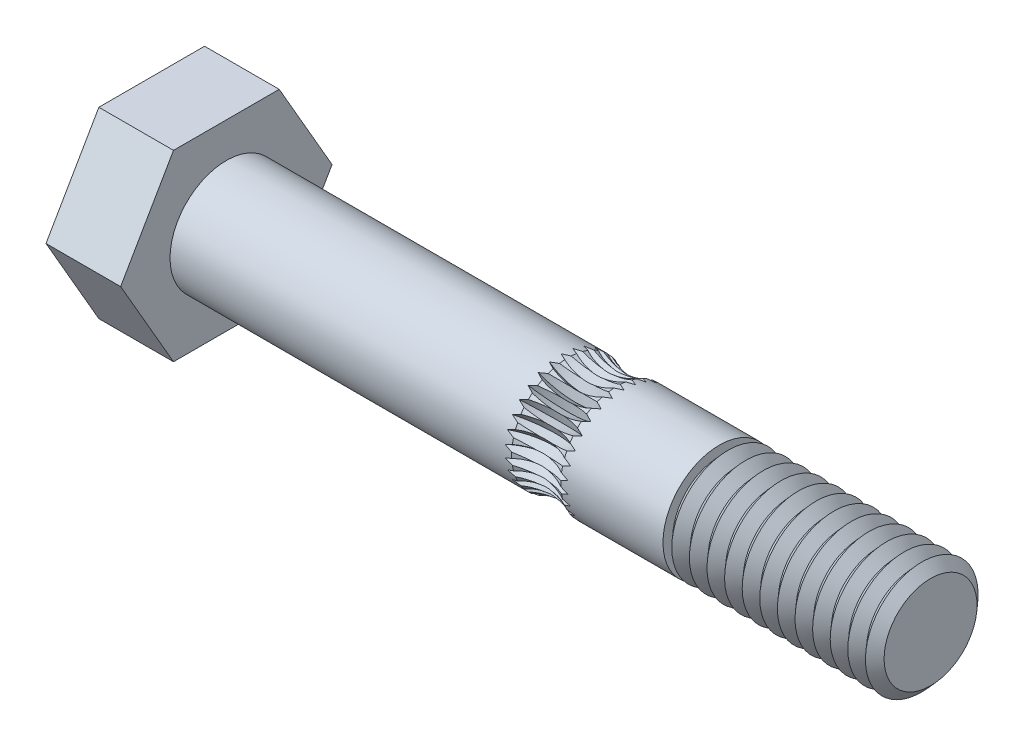
from build123d import *

# Parameters (mm, degrees)
SKETCH2_OUTSIDE_W  = 36.232
SKETCH2_OUTSIDE_H  = 36.232
CUT_EXTRUDE1_DEPTH = 66.3
CIRPATTERN1_COUNT  = 30
SKETCH4_R          = 8.784021567
CUT_EXTRUDE2_DEPTH = 10


with BuildPart() as part:
    # Sketch1 → Revolve1 (revolve)
    with BuildSketch(Plane.XY, mode=Mode.PRIVATE) as revolve1_sk:
        with BuildLine():
            Line((0, 0), (0, 10))
            Line((0, 10), (5.3, 10))
            Line((5.3, 10), (5.3, 4))
            Line((5.3, 4), (29.556440423, 4))
            ThreePointArc((29.556440423, 4), (31.3, 3.6), (33.043559577, 4))
            Line((33.043559577, 4), (40.3, 4))
            Line((40.3, 4), (40.3, 3.3))
            Line((40.3, 3.3), (40.925, 4))
            Line((40.925, 4), (41.55, 3.3))
            Line((41.55, 3.3), (42.175, 4))
            Line((42.175, 4), (42.8, 3.3))
            Line((42.8, 3.3), (43.425, 4))
            Line((43.425, 4), (44.05, 3.3))
            Line((44.05, 3.3), (44.675, 4))
            Line((44.675, 4), (45.3, 3.3))
            Line((45.3, 3.3), (45.925, 4))
            Line((45.925, 4), (46.55, 3.3))
            Line((46.55, 3.3), (47.175, 4))
            Line((47.175, 4), (47.8, 3.3))
            Line((47.8, 3.3), (48.425, 4))
            Line((48.425, 4), (49.05, 3.3))
            Line((49.05, 3.3), (49.675, 4))
            Line((49.675, 4), (50.3, 3.3))
            Line((50.3, 3.3), (50.925, 4))
            Line((50.925, 4), (51.55, 3.3))
            Line((51.55, 3.3), (52.175, 4))
            Line((52.175, 4), (52.8, 3.3))
            Line((52.8, 3.3), (53.425, 4))
            Line((53.425, 4), (54.05, 3.3))
            Line((54.05, 3.3), (54.675, 4))
            Line((54.675, 4), (55.3, 3.3))
            Line((55.3, 3.3), (55.925, 4))
            Line((55.925, 4), (56.55, 3.3))
            Line((56.55, 3.3), (57.175, 4))
            Line((57.175, 4), (57.8, 3.3))
            Line((57.8, 3.3), (58.425, 4))
            Line((58.425, 4), (59.05, 3.3))
            Line((59.05, 3.3), (59.675, 4))
            Line((59.675, 4), (60.3, 3.3))
            Line((60.3, 3.3), (60.925, 4))
            Line((60.925, 4), (61.55, 3.3))
            Line((61.55, 3.3), (62.175, 4))
            Line((62.175, 4), (62.8, 3.3))
            Line((62.8, 3.3), (63.425, 4))
            Line((63.425, 4), (64.05, 3.3))
            Line((64.05, 3.3), (64.675, 4))
            Line((64.675, 4), (65.3, 3.3))
            Line((65.3, 3.3), (65.3, 0))
            Line((65.3, 0), (0, 0))
        make_face()
    revolve(revolve1_sk.sketch.rotate(Axis((0, 0, 0), (1, 0, 0)), 90), axis=Axis((0, 0, 0), (1, 0, 0)))  # turned: the seam where the file's is

    # Sketch2 outside → Cut-Extrude1 (cut, through all)
    with BuildSketch(Plane.ZY):
        Rectangle(SKETCH2_OUTSIDE_W, SKETCH2_OUTSIDE_H)
        Polygon((3.75277675, 6.5), (-3.75277675, 6.5), (-7.505553499, 0), (-3.75277675, -6.5), (3.75277675, -6.5), (7.505553499, 0), align=None, mode=Mode.SUBTRACT)
    extrude(amount=-CUT_EXTRUDE1_DEPTH, mode=Mode.SUBTRACT)

    # Sketch3 → Cut-Revolve1 (revolve, cut)
    with BuildSketch(Plane(origin=(31.3, 0, 0), x_dir=(0, 0, -1), z_dir=(1, 0, 0))):
        Polygon((0, 3), (0.5, 3.75), (-0.5, 3.75), align=None)
    cut_revolve1 = revolve(axis=Axis((31.3, 6, 1.918700795), (0, 0, -1)), mode=Mode.SUBTRACT)

    # CirPattern1: Cut-Revolve1 ×30 about axis
    cirpattern1_axis = Axis((0, 0, 0), (-1, 0, 0))
    for i in range(1, CIRPATTERN1_COUNT):
        add(cut_revolve1.rotate(cirpattern1_axis, i * 360 / CIRPATTERN1_COUNT), mode=Mode.SUBTRACT)

    # Sketch4 → Cut-Extrude2 (cut)
    with BuildSketch(Plane(origin=(65.3, 0, 0), x_dir=(0, 0, -1), z_dir=(1, 0, 0))):
        Circle(SKETCH4_R)
    extrude(amount=-CUT_EXTRUDE2_DEPTH, mode=Mode.SUBTRACT)


solid = part.part
